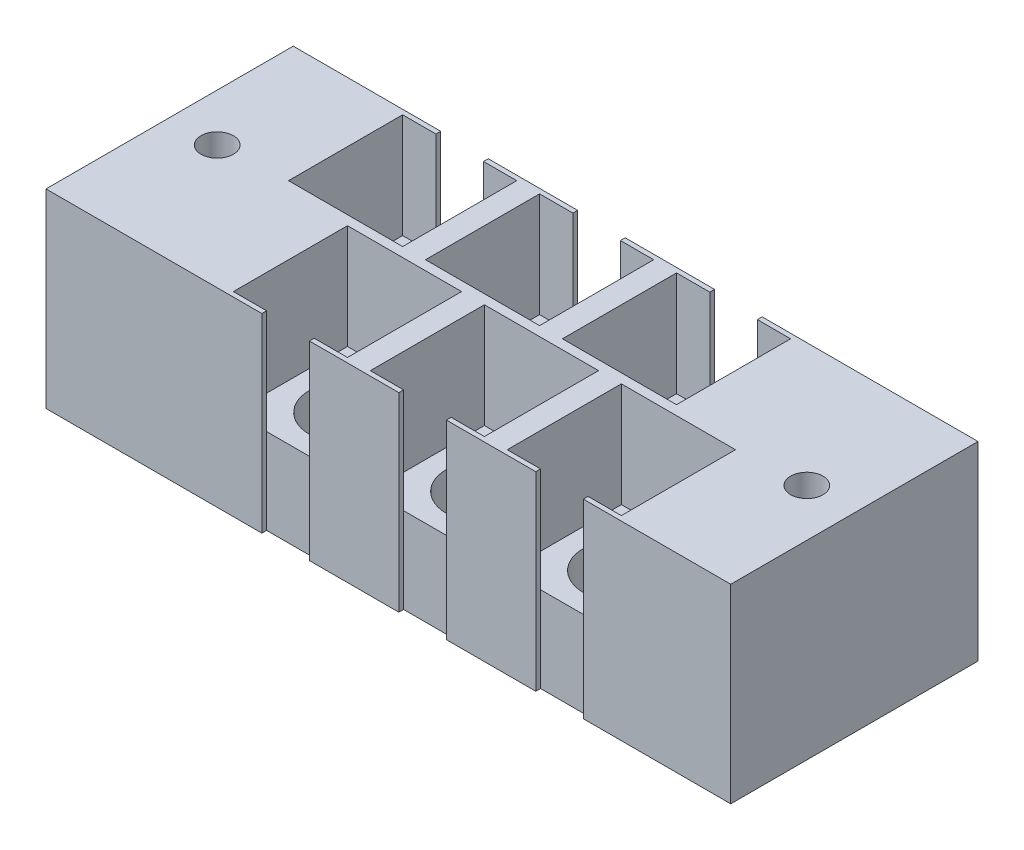
from build123d import *

# Parameters (mm, degrees)
SKETCH1_W             = 12
SKETCH1_H             = 12
SKETCH1_R             = 4
BOSS_EXTRUDE1_DEPTH   = 9
BOSS_EXTRUDE1_2_DEPTH = 9
BOSS_EXTRUDE1_3_DEPTH = 9
BOSS_EXTRUDE1_4_DEPTH = 9
BOSS_EXTRUDE1_5_DEPTH = 9
BOSS_EXTRUDE1_6_DEPTH = 9
SKETCH1_4_R           = 1.7
BOSS_EXTRUDE2_DEPTH   = 20
SKETCH2_W             = 2.2
SKETCH2_H             = 5.00000001
BOSS_EXTRUDE3_DEPTH   = 4
BOSS_EXTRUDE4_DEPTH   = 1
CUT_EXTRUDE1_DEPTH    = 1


with BuildPart() as part:
    # Sketch1 → Boss-Extrude1 (new body)
    with BuildSketch(Plane(origin=(0, 0, 0), x_dir=(1, 0, 0), z_dir=(0, 1, 0))):
        with Locations((-0.31361246, -10.664883002)):
            Rectangle(SKETCH1_W, SKETCH1_H)
        with Locations((-0.31361246, -10.664883002)):
            Circle(SKETCH1_R, mode=Mode.SUBTRACT)
    extrude(amount=BOSS_EXTRUDE1_DEPTH)



with BuildPart() as body_2:
    # Sketch1 → Boss-Extrude1 2 (new body)
    with BuildSketch(Plane(origin=(0, 0, 0), x_dir=(1, 0, 0), z_dir=(0, 1, 0))):
        with Locations((14.08638754, -10.664883022)):
            Rectangle(SKETCH1_W, SKETCH1_H)
        with Locations((14.08638754, -10.664883022)):
            Circle(SKETCH1_R, mode=Mode.SUBTRACT)
    extrude(amount=BOSS_EXTRUDE1_2_DEPTH)


with BuildPart() as body_3:
    # Sketch1 → Boss-Extrude1 3 (new body)
    with BuildSketch(Plane(origin=(0, 0, 0), x_dir=(1, 0, 0), z_dir=(0, 1, 0))):
        with Locations((6.88638754, -23.664883012)):
            Rectangle(SKETCH1_W, SKETCH1_H)
        with Locations((6.88638754, -23.664883012)):
            Circle(SKETCH1_R, mode=Mode.SUBTRACT)
    extrude(amount=BOSS_EXTRUDE1_3_DEPTH)


with BuildPart() as body_4:
    # Sketch1 → Boss-Extrude1 4 (new body)
    with BuildSketch(Plane(origin=(0, 0, 0), x_dir=(1, 0, 0), z_dir=(0, 1, 0))):
        with Locations((21.28638754, -23.664883033)):
            Rectangle(SKETCH1_W, SKETCH1_H)
        with Locations((21.28638754, -23.664883033)):
            Circle(SKETCH1_R, mode=Mode.SUBTRACT)
    extrude(amount=BOSS_EXTRUDE1_4_DEPTH)


with BuildPart() as body_5:
    # Sketch1 → Boss-Extrude1 5 (new body)
    with BuildSketch(Plane(origin=(0, 0, 0), x_dir=(1, 0, 0), z_dir=(0, 1, 0))):
        with Locations((28.48638754, -10.664883043)):
            Rectangle(SKETCH1_W, SKETCH1_H)
        with Locations((28.48638754, -10.664883043)):
            Circle(SKETCH1_R, mode=Mode.SUBTRACT)
    extrude(amount=BOSS_EXTRUDE1_5_DEPTH)


with BuildPart() as body_6:
    # Sketch1 → Boss-Extrude1 6 (new body)
    with BuildSketch(Plane(origin=(0, 0, 0), x_dir=(1, 0, 0), z_dir=(0, 1, 0))):
        with Locations((35.68638754, -23.664883053)):
            Rectangle(SKETCH1_W, SKETCH1_H)
        with Locations((35.68638754, -23.664883053)):
            Circle(SKETCH1_R, mode=Mode.SUBTRACT)
    extrude(amount=BOSS_EXTRUDE1_6_DEPTH)


with BuildPart() as part_1:
    add(part.part)

    add(body_2.part)  # Boss-Extrude2 merges body 2

    add(body_3.part)  # Boss-Extrude2 merges body 3

    add(body_4.part)  # Boss-Extrude2 merges body 4

    add(body_5.part)  # Boss-Extrude2 merges body 5

    add(body_6.part)  # Boss-Extrude2 merges body 6
    # Sketch1_4 → Boss-Extrude2 (add)
    with BuildSketch(Plane(origin=(0, 0, 0), x_dir=(1, 0, 0), z_dir=(0, 1, 0))):
        Polygon((7.58638754, -4.164883022), (6.18638754, -4.164883002), (2.18638754, -4.164883002), (2.18638754, -4.664883002), (5.68638754, -4.664883002), (5.68638754, -16.664883002), (-6.31361246, -16.664883002), (-6.31361246, -4.664883002), (-2.81361246, -4.664883002), (-2.81361246, -4.164883002), (-18.31361246, -4.164883002), (-18.31361246, -30.164883012), (4.38638754, -30.164883012), (4.38638754, -29.664883012), (0.88638754, -29.664883012), (0.88638754, -17.664883012), (12.88638754, -17.664883012), (12.88638754, -29.664883012), (9.38638754, -29.664883012), (9.38638754, -30.164883012), (13.38638754, -30.164883012), (14.78638754, -30.164883033), (18.78638754, -30.164883033), (18.78638754, -29.664883033), (15.28638754, -29.664883033), (15.28638754, -17.664883033), (27.28638754, -17.664883033), (27.28638754, -29.664883033), (23.78638754, -29.664883033), (23.78638754, -30.164883033), (27.78638754, -30.164883033), (29.18638754, -30.164883053), (33.18638754, -30.164883053), (33.18638754, -29.664883053), (29.68638754, -29.664883053), (29.68638754, -17.664883053), (41.68638754, -17.664883053), (41.68638754, -29.664883053), (38.18638754, -29.664883053), (38.18638754, -30.164883053), (42.18638754, -30.164883053), (53.68638754, -30.164883012), (53.68638754, -4.164883002), (34.98638754, -4.164883043), (30.98638754, -4.164883043), (30.98638754, -4.664883043), (34.48638754, -4.664883043), (34.48638754, -16.664883043), (22.48638754, -16.664883043), (22.48638754, -4.664883043), (25.98638754, -4.664883043), (25.98638754, -4.164883043), (21.98638754, -4.164883043), (20.58638754, -4.164883022), (16.58638754, -4.164883022), (16.58638754, -4.664883022), (20.08638754, -4.664883022), (20.08638754, -16.664883022), (8.08638754, -16.664883022), (8.08638754, -4.664883022), (11.58638754, -4.664883022), (11.58638754, -4.164883022), align=None)
        with Locations((-13.31361246, -17.164883007)):
            Circle(SKETCH1_4_R, mode=Mode.SUBTRACT)
        with Locations((48.68638754, -17.164883007)):
            Circle(SKETCH1_4_R, mode=Mode.SUBTRACT)
    extrude(amount=BOSS_EXTRUDE2_DEPTH)

    # Sketch2 → Boss-Extrude3 (add)
    with BuildSketch(Plane.XZ):
        with Locations((3.28638754, 17.164883007)):
            Rectangle(SKETCH2_W, SKETCH2_H)
        with Locations((10.48638754, 17.164883023)):
            Rectangle(SKETCH2_W, SKETCH2_H)
        with Locations((17.68638754, 17.164883038)):
            Rectangle(SKETCH2_W, SKETCH2_H)
        with Locations((24.88638754, 17.164883045)):
            Rectangle(SKETCH2_W, SKETCH2_H)
        with Locations((32.08638754, 17.164883007)):
            Rectangle(SKETCH2_W, SKETCH2_H)
    extrude(amount=BOSS_EXTRUDE3_DEPTH)

    # Sketch3 → Boss-Extrude4 (add)
    with BuildSketch(Plane.XZ):
        Polygon((-10.262781623, 27.059918831), (-8.715986751, 27.059918831), (-8.715986751, 26.734277806), (-9.977845725, 26.734277806), (-9.977845725, 25.757354729), (-8.715986751, 25.757354729), (-8.715986751, 25.431713703), (-9.977845725, 25.431713703), (-9.977845725, 23.884918831), (-10.262781623, 23.884918831), align=None)
        Polygon((-7.75623615, 27.059918831), (-7.169191879, 27.059918831), (-7.169191879, 23.884918831), (-7.454127777, 23.884918831), (-7.454127777, 26.734277806), (-7.942589315, 26.734277806), align=None)
    extrude(amount=-BOSS_EXTRUDE4_DEPTH)

    # Sketch3_2 → Cut-Extrude1 (cut)
    with BuildSketch(Plane.XZ):
        Polygon((-10.262781623, 27.059918831), (-8.715986751, 27.059918831), (-8.715986751, 26.734277806), (-9.977845725, 26.734277806), (-9.977845725, 25.757354729), (-8.715986751, 25.757354729), (-8.715986751, 25.431713703), (-9.977845725, 25.431713703), (-9.977845725, 23.884918831), (-10.262781623, 23.884918831), align=None)
        Polygon((-7.75623615, 27.059918831), (-7.169191879, 27.059918831), (-7.169191879, 23.884918831), (-7.454127777, 23.884918831), (-7.454127777, 26.734277806), (-7.942589315, 26.734277806), align=None)
    extrude(amount=-CUT_EXTRUDE1_DEPTH, mode=Mode.SUBTRACT)


solid = part_1.part
